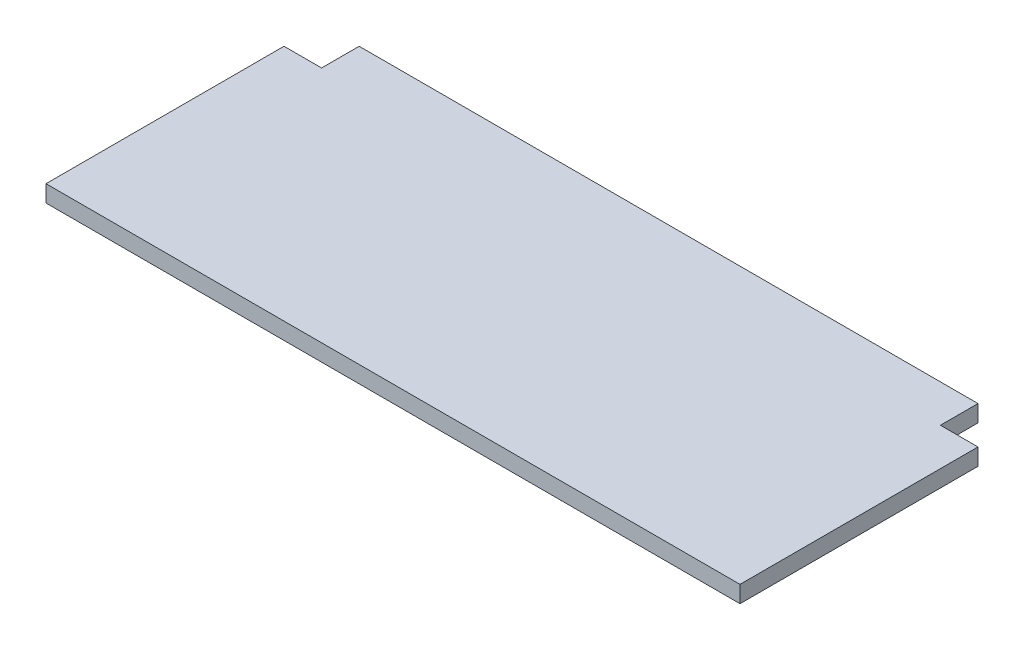
from build123d import *

# Parameters (mm, degrees)
BOSS_EXTRUDE2_DEPTH = 17.018


with BuildPart() as part:
    # Sketch1 → Boss-Extrude2 (new body)
    with BuildSketch(Plane(origin=(0, 0, 0), x_dir=(1, 0, 0), z_dir=(0, 1, 0))):
        Polygon((-351.79, -139.7), (351.79, -139.7), (351.79, 101.6), (313.69, 101.6), (313.69, 139.7), (-313.69, 139.7), (-313.69, 101.6), (-351.79, 101.6), align=None)
    extrude(amount=BOSS_EXTRUDE2_DEPTH)


solid = part.part
